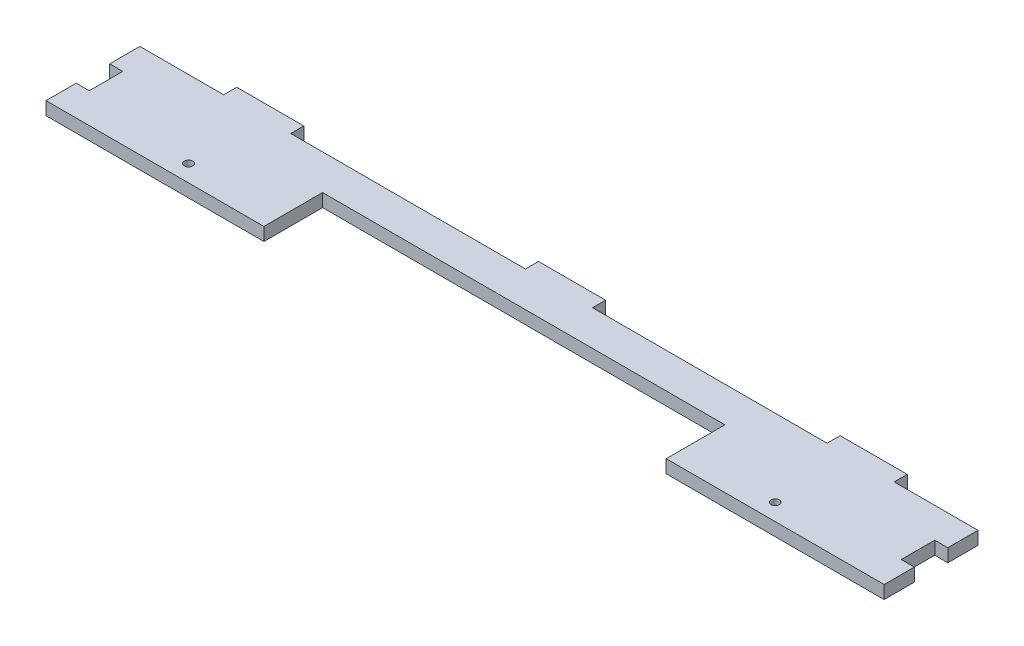
from build123d import *

# Parameters (mm, degrees)
SKETCH1_R           = 1.25
BOSS_EXTRUDE1_DEPTH = 3.9


with BuildPart() as part:
    # Sketch1 → Boss-Extrude1 (new body)
    with BuildSketch(Plane(origin=(0, 0, 0), x_dir=(1, 0, 0), z_dir=(0, 1, 0))):
        Polygon((-100, 14), (-125, 14), (-125, 5), (-121.1, 5), (-121.1, -5), (-125, -5), (-125, -14), (-60, -14), (-60, 3.5), (60, 3.5), (60, -14), (125, -14), (125, -5), (121.1, -5), (121.1, 5), (125, 5), (125, 14), (100, 14), (100, 17.9), (80, 17.9), (80, 14), (10, 14), (10, 17.9), (-10, 17.9), (-10, 14), (-80, 14), (-80, 17.9), (-100, 17.9), align=None)
        with Locations((-87.5, -9)):
            Circle(SKETCH1_R, mode=Mode.SUBTRACT)
        with Locations((87.5, -9)):
            Circle(SKETCH1_R, mode=Mode.SUBTRACT)
    extrude(amount=BOSS_EXTRUDE1_DEPTH)


solid = part.part
